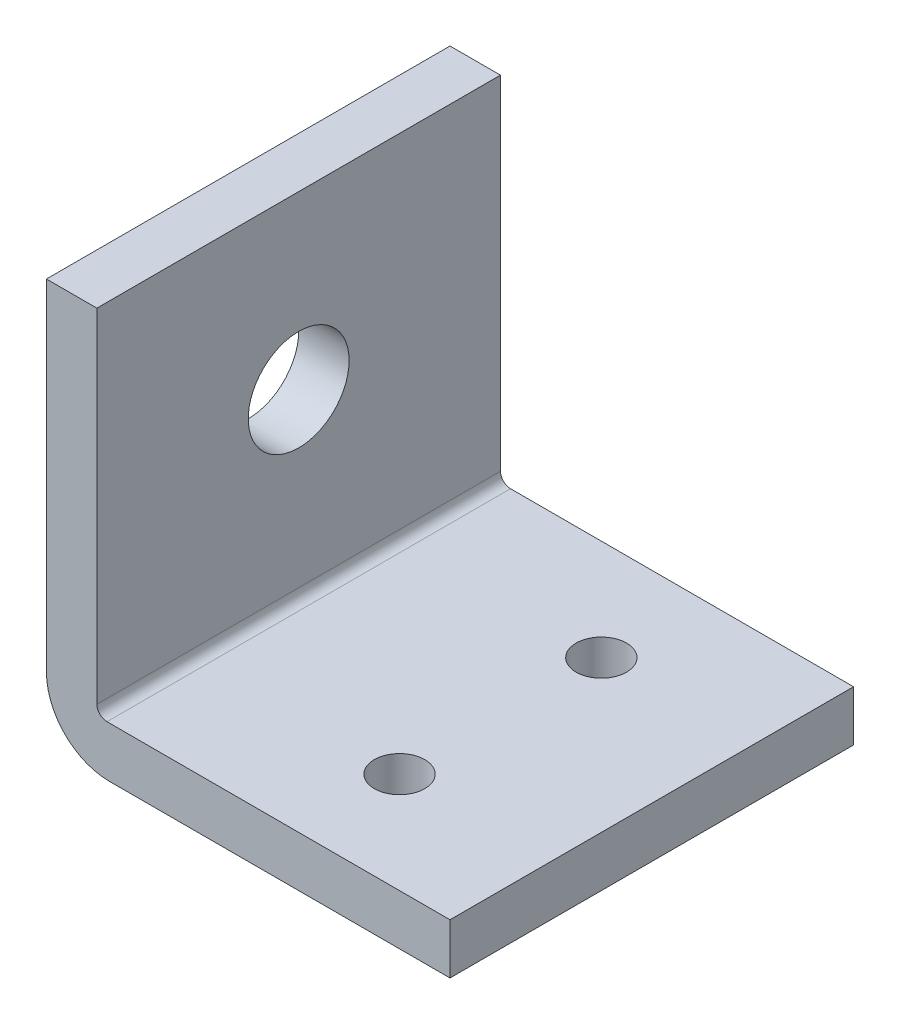
from build123d import *

# Parameters (mm, degrees)
SKETCH1_W           = 40
SKETCH1_H           = 40
BOSS_EXTRUDE1_DEPTH = 2.5
SKETCH2_W           = 5
SKETCH2_H           = 40
BOSS_EXTRUDE2_DEPTH = 35
FILLET2_R           = 6.25
FILLET3_R           = 1
SKETCH3_R           = 2.5
CUT_EXTRUDE1_DEPTH  = 5
SKETCH4_R           = 5
CUT_EXTRUDE2_DEPTH  = 5


with BuildPart() as part:
    # Sketch1 → Boss-Extrude1 (new body, symmetric)
    with BuildSketch(Plane(origin=(0, 0, 0), x_dir=(1, 0, 0), z_dir=(0, 1, 0))):
        Rectangle(SKETCH1_W, SKETCH1_H)
    extrude(amount=BOSS_EXTRUDE1_DEPTH, both=True)

    # Sketch2 → Boss-Extrude2 (add)
    with BuildSketch(Plane(origin=(0, 2.5, 0), x_dir=(1, 0, 0), z_dir=(0, 1, 0))):
        with Locations((-17.5, 0)):
            Rectangle(SKETCH2_W, SKETCH2_H)
    extrude(amount=BOSS_EXTRUDE2_DEPTH)

    # Fillet2
    fillet2_edges = [part.edges().sort_by_distance(p)[0] for p in [
        (-20, -2.5, 0),
    ]]
    fillet(fillet2_edges, radius=FILLET2_R)

    # Fillet3
    fillet3_edges = [part.edges().sort_by_distance(p)[0] for p in [
        (-15, 2.5, 0),
    ]]
    fillet(fillet3_edges, radius=FILLET3_R)

    # Sketch3 → Cut-Extrude1 (cut)
    with BuildSketch(Plane(origin=(0, 2.5, 0), x_dir=(1, 0, 0), z_dir=(0, 1, 0))):
        with Locations((5, 10)):
            Circle(SKETCH3_R)
        with Locations((5, -10)):
            Circle(SKETCH3_R)
    extrude(amount=-CUT_EXTRUDE1_DEPTH, mode=Mode.SUBTRACT)

    # Sketch4 → Cut-Extrude2 (cut)
    with BuildSketch(Plane(origin=(-15, 0, 0), x_dir=(0, 0, -1), z_dir=(1, 0, 0))):
        with Locations((0, 20.5)):
            Circle(SKETCH4_R)
    extrude(amount=-CUT_EXTRUDE2_DEPTH, mode=Mode.SUBTRACT)


solid = part.part
